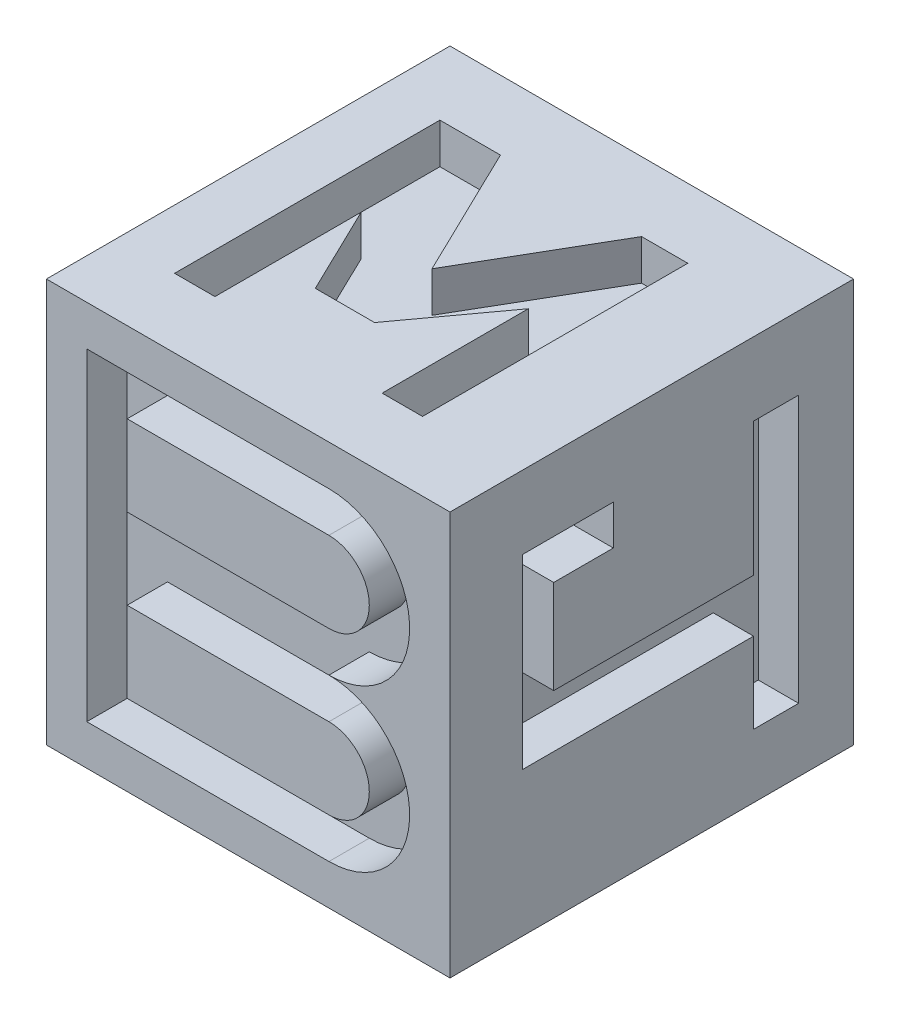
from build123d import *

# Parameters (mm, degrees)
SKETCH1_W           = 10
SKETCH1_H           = 10
BOSS_EXTRUDE1_DEPTH = 10
CUT_EXTRUDE1_DEPTH  = 1
CUT_EXTRUDE2_DEPTH  = 1
CUT_EXTRUDE3_DEPTH  = 1
SKETCH5_W           = 2.238729714
SKETCH5_H           = 2.608108567
CUT_EXTRUDE4_DEPTH  = 1
CUT_EXTRUDE5_DEPTH  = 1
CUT_EXTRUDE6_DEPTH  = 1


with BuildPart() as part:
    # Sketch1 → Boss-Extrude1 (new body)
    with BuildSketch(Plane(origin=(0, 0, 0), x_dir=(1, 0, 0), z_dir=(0, 1, 0))):
        with Locations((5, 5)):
            Rectangle(SKETCH1_W, SKETCH1_H)
    extrude(amount=BOSS_EXTRUDE1_DEPTH)

    # Sketch2 → Cut-Extrude1 (cut)
    with BuildSketch(Plane(origin=(0, 10, 0), x_dir=(1, 0, 0), z_dir=(0, 1, 0))):
        Polygon((1.465466964, 1.710070359), (1.465466964, 8.284227428), (2.964562162, 8.284227428), (4.557350811, 4.997148894), (6.462450959, 8.284227428), (7.608638796, 8.284227428), (7.608638796, 1.710070359), (6.608638796, 1.710070359), (6.608638796, 5.332883756), (5.000234573, 3.131087683), (3.532370524, 3.131087683), (2.465466964, 5.332883756), (2.465466964, 1.710070359), align=None)
    extrude(amount=-CUT_EXTRUDE1_DEPTH, mode=Mode.SUBTRACT)

    # Sketch3 → Cut-Extrude2 (cut)
    with BuildSketch(Plane(origin=(10, 0, 0), x_dir=(0, 0, -1), z_dir=(1, 0, 0))):
        Polygon((8.63868002, 8.189348455), (8.63868002, 1.575196843), (7.522328424, 1.575196843), (7.522328424, 3.574876892), (1.797107491, 3.574876892), (1.797107491, 8.189348455), (4.047324941, 8.189348455), (4.047324941, 7.203608146), (2.569618508, 7.203608146), (2.569618508, 4.882272649), (7.522328424, 4.882272649), (7.522328424, 8.189348455), align=None)
    extrude(amount=-CUT_EXTRUDE2_DEPTH, mode=Mode.SUBTRACT)

    # Sketch4 → Cut-Extrude3 (cut)
    with BuildSketch(Plane.XZ):
        Polygon((7.109235008, -8.151746998), (2.677244084, -8.151746998), (2.677244084, -7.107897794), (4.283200213, -7.107897794), (4.283200213, -3.06528113), (2.436930969, -3.06528113), (2.436930969, -1.906165647), (8.875026218, -1.906165647), (8.875026218, -3.55360609), (6.449771082, -3.55360609), (6.449771082, -7.107897794), (7.109235008, -7.107897794), align=None)
    extrude(amount=-CUT_EXTRUDE3_DEPTH, mode=Mode.SUBTRACT)

    # Sketch5 → Cut-Extrude4 (cut)
    with BuildSketch(Plane.ZY):
        Polygon((-1.636879665, 2.166406858), (-8.437777795, 2.166406858), (-8.437777795, 7.84825918), (-1.636879665, 7.84825918), (-1.636879665, 6.537193973), (-4.003754487, 6.537193973), (-4.003754487, 3.929085406), (-1.636879665, 3.929085406), align=None)
        with Locations((-6.156693587, 5.23313969)):
            Rectangle(SKETCH5_W, SKETCH5_H, mode=Mode.SUBTRACT)
    extrude(amount=-CUT_EXTRUDE4_DEPTH, mode=Mode.SUBTRACT)

    # Sketch6 → Cut-Extrude5 (cut)
    with BuildSketch(Plane(origin=(0, 0, -10), x_dir=(-1, 0, 0), z_dir=(0, 0, -1))):
        Polygon((-9, 9), (-1, 9), (-1, 8), (-4.5, 8), (-4.5, 1), (-5.5, 1), (-5.5, 8), (-9, 8), align=None)
    extrude(amount=-CUT_EXTRUDE5_DEPTH, mode=Mode.SUBTRACT)

    # Sketch7 → Cut-Extrude6 (cut)
    with BuildSketch(Plane.XY):
        with BuildLine():
            ThreePointArc((7, 5), (9, 3), (7, 1))
            Line((7, 1), (1, 1))
            Line((1, 1), (1, 9))
            Line((1, 9), (7, 9))
            ThreePointArc((7, 9), (9, 7), (7, 5))
        make_face()
        with BuildLine():
            Line((2, 8), (7, 8))
            ThreePointArc((7, 8), (8, 7), (7, 6))
            Line((7, 6), (2, 6))
            Line((2, 6), (2, 8))
        make_face(mode=Mode.SUBTRACT)
        with BuildLine():
            Line((7, 4), (2, 4))
            Line((2, 4), (2, 2))
            Line((2, 2), (7, 2))
            ThreePointArc((7, 2), (8, 3), (7, 4))
        make_face(mode=Mode.SUBTRACT)
    extrude(amount=-CUT_EXTRUDE6_DEPTH, mode=Mode.SUBTRACT)


solid = part.part
